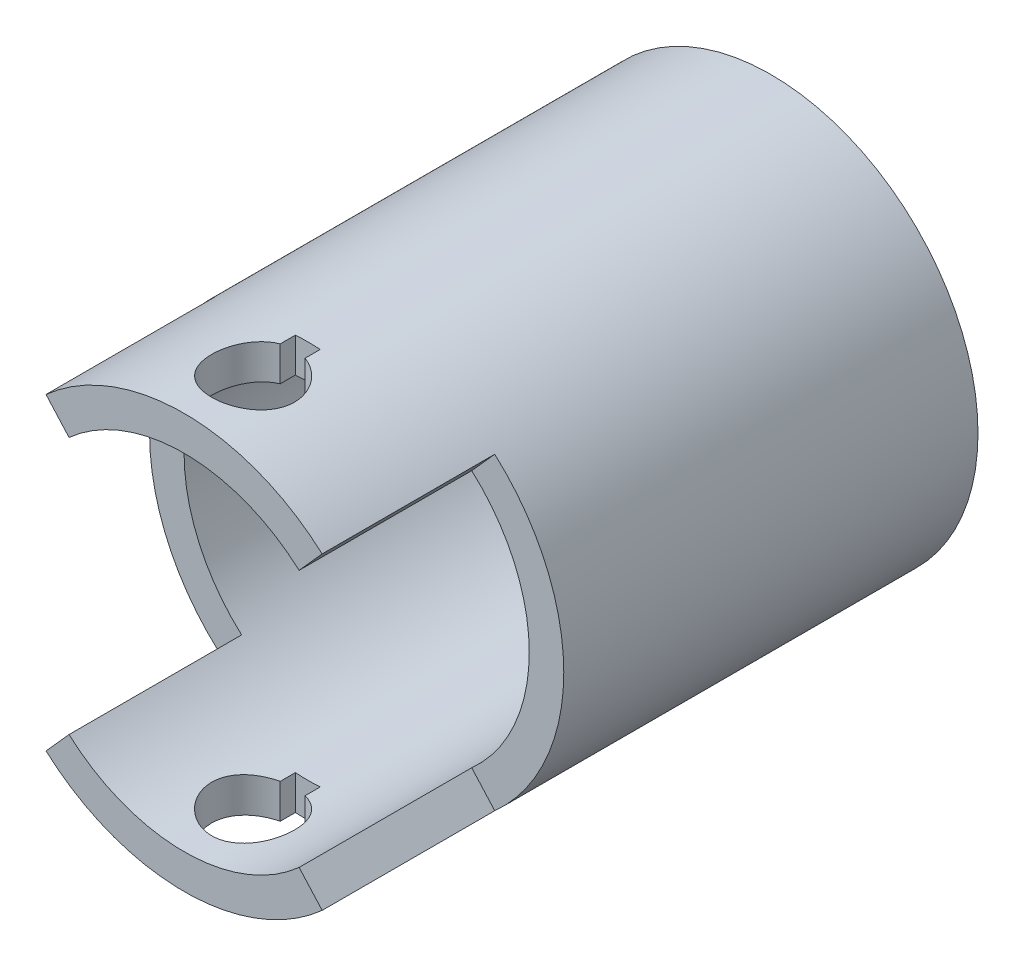
from build123d import *

# Parameters (mm, degrees)
SKETCH1_R           = 15
SKETCH1_R_2         = 12.5
BOSS_EXTRUDE1_DEPTH = 30
BOSS_EXTRUDE2_DEPTH = 12.5
CUT_EXTRUDE1_DEPTH  = 35


with BuildPart() as part:
    # Sketch1 → Boss-Extrude1 (new body)
    with BuildSketch(Plane(origin=(0, 0, 0), x_dir=(0, 1, 0), z_dir=(0, 0, 1))):
        Circle(SKETCH1_R)
        Circle(SKETCH1_R_2, mode=Mode.SUBTRACT)
    extrude(amount=BOSS_EXTRUDE1_DEPTH)

    # Sketch4 → Boss-Extrude2 (add)
    with BuildSketch(Plane.XY.offset(30)):
        with BuildLine():
            Line((-10, -11.180339887), (-8.333333333, -9.316949906))
            ThreePointArc((-8.333333333, -9.316949906), (0, -12.5), (8.333333333, -9.316949906))
            Line((8.333333333, -9.316949906), (10, -11.180339887))
            ThreePointArc((10, -11.180339887), (0, -15), (-10, -11.180339887))
        make_face()
        with BuildLine():
            Line((-10, 11.180339887), (-8.333333333, 9.316949906))
            ThreePointArc((-8.333333333, 9.316949906), (0, 12.5), (8.333333333, 9.316949906))
            Line((8.333333333, 9.316949906), (10, 11.180339887))
            ThreePointArc((10, 11.180339887), (0, 15), (-10, 11.180339887))
        make_face()
    extrude(amount=BOSS_EXTRUDE2_DEPTH)

    # Sketch6 → Cut-Extrude1 (cut)
    with BuildSketch(Plane(origin=(0, 15, 0), x_dir=(1, 0, 0), z_dir=(0, 1, 0))):
        with BuildLine():
            Line((-0.9, -34.638182396), (-0.9, -33.538182396))
            Line((-0.9, -33.538182396), (0.9, -33.538182396))
            Line((0.9, -33.538182396), (0.9, -34.638182396))
            ThreePointArc((0.9, -34.638182396), (0, -40.5), (-0.9, -34.638182396))
        make_face()
    extrude(amount=-CUT_EXTRUDE1_DEPTH, mode=Mode.SUBTRACT)


solid = part.part
